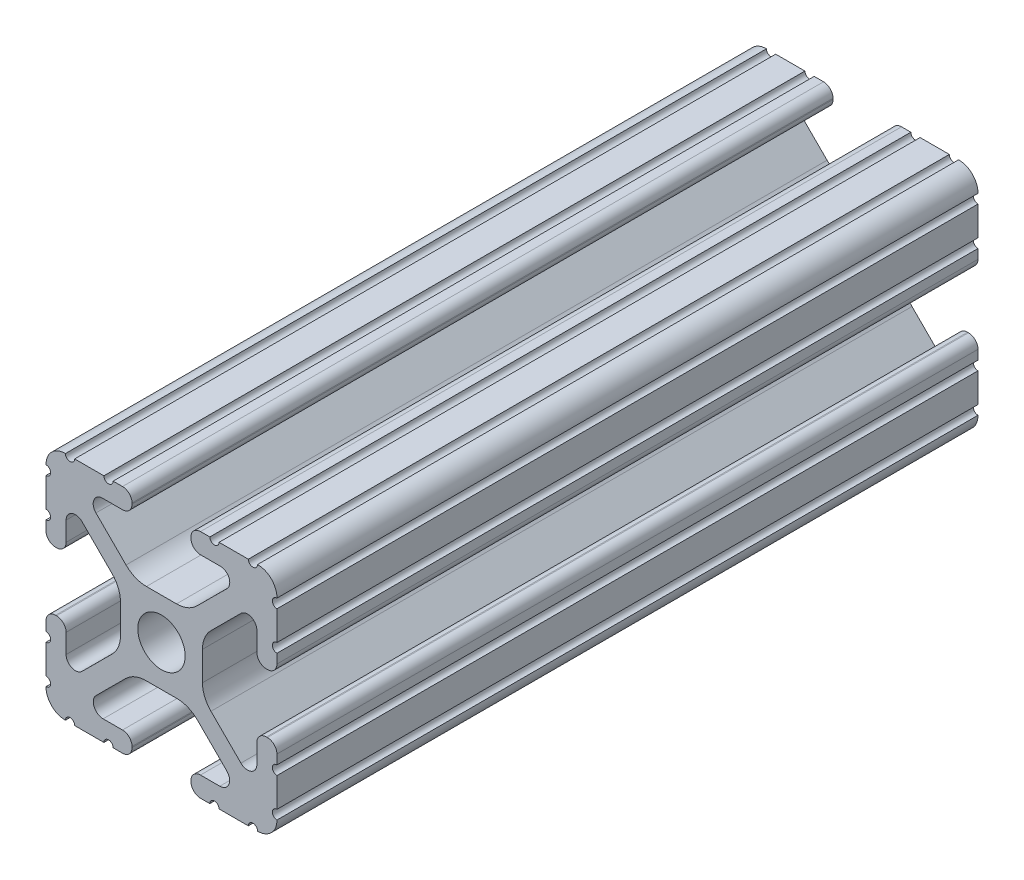
from build123d import *

# Parameters (mm, degrees)
SKETCH1_R      = 2.6035
EXTRUDE1_DEPTH = 77.1


with BuildPart() as part:
    # Sketch1 → Extrude1 (new body)
    with BuildSketch(Plane.XY):
        with BuildLine():
            Line((-7.207036008, 8.724370562), (-3.898272566, 5.423169045))
            ThreePointArc((-3.898272566, 5.423169045), (-2.869120213, 4.736787962), (-1.655778399, 4.4958))
            Line((-1.655778399, 4.4958), (1.655778399, 4.4958))
            ThreePointArc((1.655778399, 4.4958), (2.869120213, 4.736787962), (3.898272566, 5.423169045))
            Line((3.898272566, 5.423169045), (7.207036008, 8.724370562))
            ThreePointArc((7.207036008, 8.724370562), (7.432222385, 9.85140422), (6.476788598, 10.4902))
            Line((6.476788598, 10.4902), (4.287512407, 10.4902))
            ThreePointArc((4.287512407, 10.4902), (3.54574862, 10.79744862), (3.2385, 11.539212407))
            Line((3.2385, 11.539212407), (3.2385, 11.650987593))
            ThreePointArc((3.2385, 11.650987593), (3.54574862, 12.39275138), (4.287512407, 12.7))
            Line((4.287512407, 12.7), (5.317126718, 12.7))
            ThreePointArc((5.317126718, 12.7), (5.825126718, 12.192), (6.333126718, 12.7))
            Line((6.333126718, 12.7), (9.550443118, 12.7))
            ThreePointArc((9.550443118, 12.7), (10.058366869, 12.192000006), (10.566443095, 12.699847501))
            ThreePointArc((10.566443095, 12.699847501), (12.082537762, 12.08250727), (12.699846982, 10.566399977))
            ThreePointArc((12.699846982, 10.566399977), (12.192000006, 10.058323491), (12.7, 9.5504))
            Line((12.7, 9.5504), (12.7, 6.3330836))
            ThreePointArc((12.7, 6.3330836), (12.192, 5.8250836), (12.7, 5.3170836))
            Line((12.7, 5.3170836), (12.7, 4.287469289))
            ThreePointArc((12.7, 4.287469289), (12.39275138, 3.545705502), (11.650987593, 3.238456882))
            Line((11.650987593, 3.238456882), (11.539212407, 3.238456882))
            ThreePointArc((11.539212407, 3.238456882), (10.79744862, 3.545705502), (10.4902, 4.287469289))
            Line((10.4902, 4.287469289), (10.4902, 6.402089023))
            ThreePointArc((10.4902, 6.402089023), (9.856505071, 7.351067942), (8.737131347, 7.129408934))
            Line((8.737131347, 7.129408934), (5.441005833, 3.840816462))
            ThreePointArc((5.441005833, 3.840816462), (4.750877967, 2.809883091), (4.5085, 1.593185507))
            Line((4.5085, 1.593185507), (4.5085, -1.593185507))
            ThreePointArc((4.5085, -1.593185507), (4.750877967, -2.809883091), (5.441005833, -3.840816462))
            Line((5.441005833, -3.840816462), (8.737131347, -7.129408934))
            ThreePointArc((8.737131347, -7.129408934), (9.856505071, -7.351067942), (10.4902, -6.402089023))
            Line((10.4902, -6.402089023), (10.4902, -4.287469289))
            ThreePointArc((10.4902, -4.287469289), (10.79744862, -3.545705502), (11.539212407, -3.238456882))
            Line((11.539212407, -3.238456882), (11.650987593, -3.238456882))
            ThreePointArc((11.650987593, -3.238456882), (12.39275138, -3.545705502), (12.7, -4.287469289))
            Line((12.7, -4.287469289), (12.7, -5.3170836))
            ThreePointArc((12.7, -5.3170836), (12.192, -5.8250836), (12.7, -6.3330836))
            Line((12.7, -6.3330836), (12.7, -9.5504))
            ThreePointArc((12.7, -9.5504), (12.192000006, -10.058323491), (12.699846982, -10.566399977))
            ThreePointArc((12.699846982, -10.566399977), (12.082537762, -12.08250727), (10.566443095, -12.699847501))
            ThreePointArc((10.566443095, -12.699847501), (10.058366869, -12.192000006), (9.550443118, -12.7))
            Line((9.550443118, -12.7), (6.333126718, -12.7))
            ThreePointArc((6.333126718, -12.7), (5.825126718, -12.192), (5.317126718, -12.7))
            Line((5.317126718, -12.7), (4.287512407, -12.7))
            ThreePointArc((4.287512407, -12.7), (3.54574862, -12.39275138), (3.2385, -11.650987593))
            Line((3.2385, -11.650987593), (3.2385, -11.539212407))
            ThreePointArc((3.2385, -11.539212407), (3.54574862, -10.79744862), (4.287512407, -10.4902))
            Line((4.287512407, -10.4902), (6.416408329, -10.4902))
            ThreePointArc((6.416408329, -10.4902), (7.41473083, -9.822813117), (7.179650497, -8.645192506))
            Line((7.179650497, -8.645192506), (3.952270251, -5.423690499))
            ThreePointArc((3.952270251, -5.423690499), (2.922936451, -4.736929036), (1.709253557, -4.4958))
            Line((1.709253557, -4.4958), (-1.709253557, -4.4958))
            ThreePointArc((-1.709253557, -4.4958), (-2.922936451, -4.736929036), (-3.952270251, -5.423690499))
            Line((-3.952270251, -5.423690499), (-7.179650497, -8.645192506))
            ThreePointArc((-7.179650497, -8.645192506), (-7.41473083, -9.822813117), (-6.416408329, -10.4902))
            Line((-6.416408329, -10.4902), (-4.287512407, -10.4902))
            ThreePointArc((-4.287512407, -10.4902), (-3.54574862, -10.79744862), (-3.2385, -11.539212407))
            Line((-3.2385, -11.539212407), (-3.2385, -11.650987593))
            ThreePointArc((-3.2385, -11.650987593), (-3.54574862, -12.39275138), (-4.287512407, -12.7))
            Line((-4.287512407, -12.7), (-5.317126718, -12.7))
            ThreePointArc((-5.317126718, -12.7), (-5.825126718, -12.192), (-6.333126718, -12.7))
            Line((-6.333126718, -12.7), (-9.550443118, -12.7))
            ThreePointArc((-9.550443118, -12.7), (-10.058366869, -12.192000006), (-10.566443095, -12.699847501))
            ThreePointArc((-10.566443095, -12.699847501), (-12.082537762, -12.08250727), (-12.699846982, -10.566399977))
            ThreePointArc((-12.699846982, -10.566399977), (-12.192000006, -10.058323491), (-12.7, -9.5504))
            Line((-12.7, -9.5504), (-12.7, -6.3330836))
            ThreePointArc((-12.7, -6.3330836), (-12.192, -5.8250836), (-12.7, -5.3170836))
            Line((-12.7, -5.3170836), (-12.7, -4.287469289))
            ThreePointArc((-12.7, -4.287469289), (-12.39275138, -3.545705502), (-11.650987593, -3.238456882))
            Line((-11.650987593, -3.238456882), (-11.539212407, -3.238456882))
            ThreePointArc((-11.539212407, -3.238456882), (-10.79744862, -3.545705502), (-10.4902, -4.287469289))
            Line((-10.4902, -4.287469289), (-10.4902, -6.402089023))
            ThreePointArc((-10.4902, -6.402089023), (-9.856505071, -7.351067942), (-8.737131347, -7.129408934))
            Line((-8.737131347, -7.129408934), (-5.441005833, -3.840816462))
            ThreePointArc((-5.441005833, -3.840816462), (-4.750877967, -2.809883091), (-4.5085, -1.593185507))
            Line((-4.5085, -1.593185507), (-4.5085, 1.593185507))
            ThreePointArc((-4.5085, 1.593185507), (-4.750877967, 2.809883091), (-5.441005833, 3.840816462))
            Line((-5.441005833, 3.840816462), (-8.737131347, 7.129408934))
            ThreePointArc((-8.737131347, 7.129408934), (-9.856505071, 7.351067942), (-10.4902, 6.402089023))
            Line((-10.4902, 6.402089023), (-10.4902, 4.287469289))
            ThreePointArc((-10.4902, 4.287469289), (-10.79744862, 3.545705502), (-11.539212407, 3.238456882))
            Line((-11.539212407, 3.238456882), (-11.650987593, 3.238456882))
            ThreePointArc((-11.650987593, 3.238456882), (-12.39275138, 3.545705502), (-12.7, 4.287469289))
            Line((-12.7, 4.287469289), (-12.7, 5.3170836))
            ThreePointArc((-12.7, 5.3170836), (-12.192, 5.8250836), (-12.7, 6.3330836))
            Line((-12.7, 6.3330836), (-12.7, 9.5504))
            ThreePointArc((-12.7, 9.5504), (-12.192000006, 10.058323491), (-12.699846982, 10.566399977))
            ThreePointArc((-12.699846982, 10.566399977), (-12.082537762, 12.08250727), (-10.566443095, 12.699847501))
            ThreePointArc((-10.566443095, 12.699847501), (-10.058366869, 12.192000006), (-9.550443118, 12.7))
            Line((-9.550443118, 12.7), (-6.333126718, 12.7))
            ThreePointArc((-6.333126718, 12.7), (-5.825126718, 12.192), (-5.317126718, 12.7))
            Line((-5.317126718, 12.7), (-4.287512407, 12.7))
            ThreePointArc((-4.287512407, 12.7), (-3.54574862, 12.39275138), (-3.2385, 11.650987593))
            Line((-3.2385, 11.650987593), (-3.2385, 11.539212407))
            ThreePointArc((-3.2385, 11.539212407), (-3.54574862, 10.79744862), (-4.287512407, 10.4902))
            Line((-4.287512407, 10.4902), (-6.476788598, 10.4902))
            ThreePointArc((-6.476788598, 10.4902), (-7.432222385, 9.85140422), (-7.207036008, 8.724370562))
        make_face()
        Circle(SKETCH1_R, mode=Mode.SUBTRACT)
    extrude(amount=-EXTRUDE1_DEPTH)


solid = part.part
